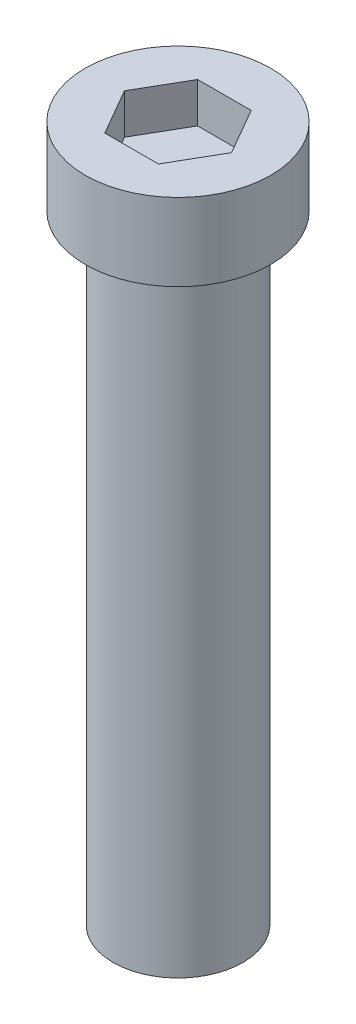
from build123d import *

# Parameters (mm, degrees)
CROQUIS1_R              = 3
SALIENTE_EXTRUIR1_DEPTH = 2.5
CROQUIS2_R              = 2.1
SALIENTE_EXTRUIR2_DEPTH = 20
CORTAR_EXTRUIR1_DEPTH   = 2.5


with BuildPart() as part:
    # Croquis1 → Saliente-Extruir1 (new body)
    with BuildSketch(Plane(origin=(0, 0, 0), x_dir=(1, 0, 0), z_dir=(0, 1, 0))):
        Circle(CROQUIS1_R)
    extrude(amount=SALIENTE_EXTRUIR1_DEPTH)

    # Croquis2 → Saliente-Extruir2 (add)
    with BuildSketch(Plane(origin=(0, 0, 0), x_dir=(1, 0, 0), z_dir=(0, 1, 0))):
        Circle(CROQUIS2_R)
    extrude(amount=-SALIENTE_EXTRUIR2_DEPTH)

    # Croquis4 → Cortar-Extruir1 (cut)
    with BuildSketch(Plane(origin=(0, 3.7, 0), x_dir=(1, 0, 0), z_dir=(0, 1, 0))):
        Polygon((1.732050808, 0), (0.866025404, 1.5), (-0.866025404, 1.5), (-1.732050808, 0), (-0.866025404, -1.5), (0.866025404, -1.5), align=None)
    extrude(amount=-CORTAR_EXTRUIR1_DEPTH, mode=Mode.SUBTRACT)


solid = part.part
